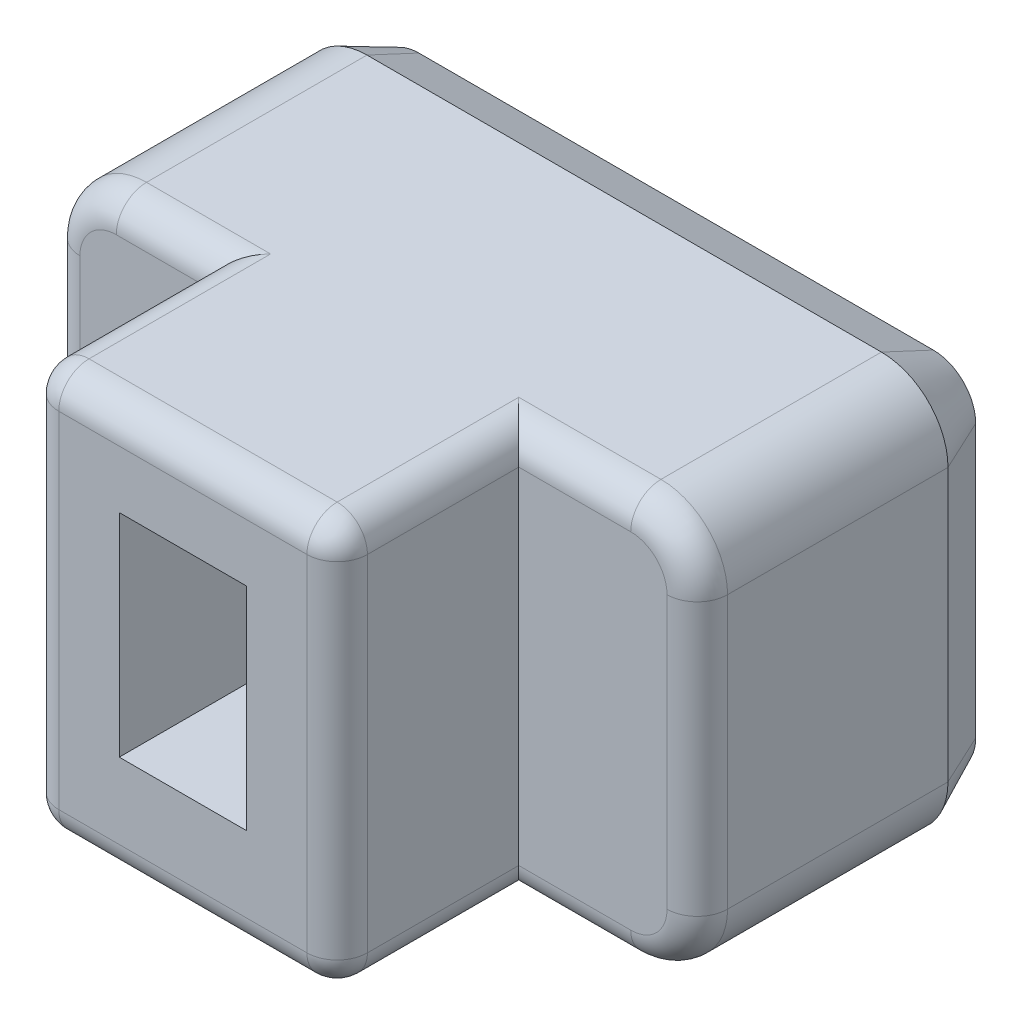
from build123d import *

# Parameters (mm, degrees)
BOSS_EXTRU_1_DEPTH      = 8
ESQUISSE3_W             = 2.1
ESQUISSE3_H             = 3.5
ENL_V_MAT_EXTRU_1_DEPTH = 3
ESQUISSE4_OUTSIDE_W     = 15.69
ESQUISSE4_OUTSIDE_H     = 11.69
ESQUISSE4_OUTSIDE_W_2   = 5.1
ESQUISSE4_OUTSIDE_H_2   = 6.7
ENL_V_MAT_EXTRU_2_DEPTH = 3
CONG_1_R                = 0.5
CHANFREIN1_SIZE         = 0.4
CHANFREIN1_SIZE2        = 0.857802768
ESQUISSE5_W             = 0.443661971
ESQUISSE5_H             = 3.5
ENL_V_MAT_EXTRU_3_DEPTH = 0.2
BOSS_EXTRU_2_DEPTH      = 0.2
BOSS_EXTRU_2_2_DEPTH    = 0.2
ESQUISSE5_4_W           = 0.443661971
ESQUISSE5_4_H           = 3.5
BOSS_EXTRU_2_3_DEPTH    = 0.2


with BuildPart() as part:
    # Esquisse2 → Boss.-Extru.1 (new body)
    with BuildSketch(Plane.XY):
        with BuildLine():
            Line((1.1, 0), (9.6, 0))
            ThreePointArc((9.6, 0), (10.377817459, 0.322182541), (10.7, 1.1))
            Line((10.7, 1.1), (10.7, 5.6))
            ThreePointArc((10.7, 5.6), (10.377817459, 6.377817459), (9.6, 6.7))
            Line((9.6, 6.7), (1.1, 6.7))
            ThreePointArc((1.1, 6.7), (0.322182541, 6.377817459), (0, 5.6))
            Line((0, 5.6), (0, 1.1))
            ThreePointArc((0, 1.1), (0.322182541, 0.322182541), (1.1, 0))
        make_face()
    extrude(amount=BOSS_EXTRU_1_DEPTH)

    # Esquisse3 → Enlèv. mat.-Extru.1 (cut)
    with BuildSketch(Plane.XY.offset(8)):
        with Locations((5.2, 3.5)):
            Rectangle(ESQUISSE3_W, ESQUISSE3_H)
    extrude(amount=-ENL_V_MAT_EXTRU_1_DEPTH, mode=Mode.SUBTRACT)

    # Esquisse4 outside → Enlèv. mat.-Extru.2 (cut)
    with BuildSketch(Plane.XY.offset(8)):
        with Locations((5.35, 3.35)):
            Rectangle(ESQUISSE4_OUTSIDE_W, ESQUISSE4_OUTSIDE_H)
        with Locations((5.2, 3.35)):
            Rectangle(ESQUISSE4_OUTSIDE_W_2, ESQUISSE4_OUTSIDE_H_2, mode=Mode.SUBTRACT)
    extrude(amount=-ENL_V_MAT_EXTRU_2_DEPTH, mode=Mode.SUBTRACT)

    # Congé1
    cong_1_edges = [part.edges().sort_by_distance(p)[0] for p in [
        (8.675, 0, 5),
        (10.377817459, 0.322182541, 5),
        (10.7, 3.35, 5),
        (10.377817459, 6.377817459, 5),
        (1.875, 6.7, 5),
        (0.322182541, 6.377817459, 5),
        (1.875, 0, 5),
        (0.322182541, 0.322182541, 5),
        (7.75, 6.7, 6.5),
        (2.65, 6.7, 6.5),
        (7.75, 0, 6.5),
        (2.65, 0, 6.5),
        (2.65, 3.35, 8),
        (5.2, 6.7, 8),
        (7.75, 3.35, 8),
        (5.2, 0, 8),
        (8.675, 6.7, 5),
        (0, 3.35, 5),
    ]]
    fillet(cong_1_edges, radius=CONG_1_R)

    # Chanfrein1
    chanfrein1_edges = [part.edges().sort_by_distance(p)[0] for p in [
        (5.35, 0, 0),
        (10.377817459, 0.322182541, 0),
        (0.322182541, 0.322182541, 0),
        (10.7, 3.35, 0),
        (0, 3.35, 0),
        (10.377817459, 6.377817459, 0),
        (0.322182541, 6.377817459, 0),
        (5.35, 6.7, 0),
    ]]
    chanfrein1_side = [part.faces().sort_by_distance(p)[0] for p in [
        (5.35, 3.35, 0),
    ]]
    chamfer(chanfrein1_edges, length=CHANFREIN1_SIZE, length2=CHANFREIN1_SIZE2, reference=chanfrein1_side[0])

    # Esquisse5 → Enlèv. mat.-Extru.3 (cut)
    # profile 1 of 3: a face of its own
    with BuildSketch(Plane.XY):
        with BuildLine():
            add(Edge.make_bspline(
                [(3.442119312, 1.938069324), (3.395066193, 1.938910772), (3.302153597, 1.940572322), (3.165772884, 1.959585223), (3.033480986, 1.9865083), (2.906821659, 2.027013155), (2.785549912, 2.077136818), (2.672670174, 2.140088534), (2.567734941, 2.213495328), (2.472020347, 2.298905726), (2.384541306, 2.394549003), (2.306892222, 2.501721356), (2.240446849, 2.620291238), (2.181769344, 2.748647547), (2.135878101, 2.888915832), (2.101782213, 3.039930676), (2.082925754, 3.20233784), (2.080192642, 3.313939587), (2.078783044, 3.371498021)],
                knots=[0, 0, 0, 0, 1.010713025, 1.995786298, 2.954820268, 3.909604824, 4.84953527, 5.771007602, 6.682058279, 7.596879091, 8.52277019, 9.463332336, 10.434705207, 11.4400245, 12.492415661, 13.601058905, 14.762749715, 16, 16, 16, 16], degree=3))
            add(Edge.make_bspline(
                [(2.078783044, 3.371498021), (2.079924859, 3.428285975), (2.082142615, 3.538585721), (2.100387971, 3.698284797), (2.132134357, 3.846191315), (2.174876342, 3.982683971), (2.230167977, 4.107269116), (2.294540482, 4.221517301), (2.370844541, 4.323766735), (2.456519919, 4.415457029), (2.552952802, 4.495031079), (2.658512678, 4.564174912), (2.773555911, 4.621942146), (2.897787738, 4.667825284), (3.02968821, 4.704210486), (3.169474567, 4.729011378), (3.316205366, 4.744852079), (3.416402337, 4.746888963), (3.467537446, 4.747928478)],
                knots=[0, 0, 0, 0, 1.222566562, 2.374601885, 3.454571273, 4.475627065, 5.44839755, 6.384388942, 7.293261178, 8.188871665, 9.080034862, 9.978575306, 10.90076714, 11.845452766, 12.825859322, 13.842986405, 14.899177044, 16, 16, 16, 16], degree=3))
            add(Edge.make_bspline(
                [(3.467537446, 4.747928478), (3.497077269, 4.747756903), (3.558017547, 4.747402944), (3.650917954, 4.740187531), (3.746845258, 4.732574634), (3.843310634, 4.719697556), (3.939155709, 4.705397767), (4.031601512, 4.688612545), (4.118094427, 4.670829677), (4.172627532, 4.656252994), (4.198501354, 4.649336929)],
                knots=[0, 0, 0, 0, 0.958487045, 1.977346509, 3.023048326, 4.081489793, 5.135130748, 6.168204709, 7.130884884, 8, 8, 8, 8], degree=3))
            Line((4.198501354, 4.649336929), (4.198501354, 5.019055239))
            add(Edge.make_bspline(
                [(4.198501354, 5.019055239), (4.171891989, 5.028574955), (4.117351664, 5.0480872), (4.031270221, 5.072848876), (3.939055541, 5.093142904), (3.807669886, 5.116831328), (3.636636044, 5.138394566), (3.497652561, 5.140986233), (3.427484629, 5.142294676)],
                knots=[0, 0, 0, 0, 0.64817905, 1.328550917, 2.052973816, 2.813122394, 4.391056218, 6, 6, 6, 6], degree=3))
            add(Edge.make_bspline(
                [(3.427484629, 5.142294676), (3.357075444, 5.140826497), (3.219995444, 5.137968093), (3.020757882, 5.115533024), (2.833971161, 5.078189546), (2.659970346, 5.024823864), (2.498802115, 4.957896391), (2.350125012, 4.878441577), (2.215448613, 4.784882224), (2.094283086, 4.677766078), (1.987140454, 4.557842568), (1.892465469, 4.425953407), (1.814624509, 4.280040443), (1.748848028, 4.123085375), (1.697006767, 3.9546993), (1.661682518, 3.774744734), (1.638427133, 3.584439174), (1.636239514, 3.453729532), (1.635121073, 3.38690295)],
                knots=[0, 0, 0, 0, 1.184649013, 2.306399189, 3.36898292, 4.385816993, 5.363947997, 6.301541167, 7.217245905, 8.117147173, 9.016695713, 9.918265376, 10.842401924, 11.79328093, 12.778666145, 13.801422125, 14.875955582, 16, 16, 16, 16], degree=3))
            add(Edge.make_bspline(
                [(1.635121073, 3.38690295), (1.63652538, 3.320843721), (1.639288242, 3.190877444), (1.663308294, 3.000284905), (1.700302314, 2.817243304), (1.754667164, 2.643460839), (1.821836851, 2.479051191), (1.904013284, 2.326258247), (1.999795792, 2.185573787), (2.10872572, 2.056935937), (2.231154394, 1.941746033), (2.365976512, 1.839579054), (2.513043826, 1.750628048), (2.672006774, 1.675953383), (2.841975297, 1.616334738), (3.022719606, 1.574247144), (3.21362756, 1.548296445), (3.344470487, 1.54525619), (3.411309453, 1.543703126)],
                knots=[0, 0, 0, 0, 1.099381571, 2.162945759, 3.193245675, 4.204563685, 5.189679354, 6.145919907, 7.087284112, 8.018274975, 8.946592887, 9.88016098, 10.829497872, 11.802783365, 12.799112124, 13.822445575, 14.887631986, 16, 16, 16, 16], degree=3))
            add(Edge.make_bspline(
                [(3.411309453, 1.543703126), (3.447001192, 1.544253256), (3.518435413, 1.545354297), (3.624419175, 1.550915785), (3.727566932, 1.563228075), (3.82638564, 1.577132749), (3.91938219, 1.595742162), (4.004794207, 1.616820876), (4.080906052, 1.640362569), (4.127469434, 1.65848355), (4.14920558, 1.666942563)],
                knots=[0, 0, 0, 0, 1.138607152, 2.278833004, 3.383081621, 4.45092605, 5.46116126, 6.40661541, 7.25619579, 8, 8, 8, 8], degree=3))
            Line((4.14920558, 1.666942563), (4.14920558, 2.036660873))
            add(Edge.make_bspline(
                [(4.14920558, 2.036660873), (4.095425956, 2.023181548), (3.983688555, 1.995175686), (3.809263405, 1.9649167), (3.62732109, 1.94170611), (3.503813346, 1.939280802), (3.442119312, 1.938069324)],
                knots=[0, 0, 0, 0, 0.92915897, 1.930504546, 2.966254919, 4, 4, 4, 4], degree=3))
        make_face()
    # profile 2 of 3: a face of its own
    with BuildSketch(Plane.XY):
        with BuildLine():
            add(Edge.make_bspline(
                [(7.747797129, 3.327593971), (7.746919878, 3.377945997), (7.745193276, 3.477048625), (7.731197663, 3.623559869), (7.706970704, 3.765198254), (7.675164776, 3.902660023), (7.632949757, 4.034428836), (7.580365712, 4.159552876), (7.518574412, 4.277839122), (7.447611708, 4.389517104), (7.366196496, 4.493311013), (7.276824072, 4.591258519), (7.176888246, 4.680552099), (7.067749349, 4.762660281), (6.948916125, 4.836610737), (6.820485318, 4.901932876), (6.682998819, 4.959797651), (6.586304596, 4.989345019), (6.536969664, 5.004420556)],
                knots=[0, 0, 0, 0, 1.07890696, 2.123499795, 3.15014457, 4.15640317, 5.144722051, 6.111393237, 7.061337734, 8.001528439, 8.942523758, 9.884837156, 10.839359572, 11.809921804, 12.808388495, 13.834502369, 14.895128641, 16, 16, 16, 16], degree=3))
            add(Edge.make_bspline(
                [(6.536969664, 5.004420556), (6.477123779, 5.019478053), (6.353629302, 5.050549824), (6.157038434, 5.075157068), (5.945699193, 5.091007195), (5.799366536, 5.092319391), (5.723589382, 5.092998901)],
                knots=[0, 0, 0, 0, 0.901675841, 1.860645644, 2.892153085, 4, 4, 4, 4], degree=3))
            Line((5.723589382, 5.092998901), (4.937937974, 5.092998901))
            Line((4.937937974, 5.092998901), (4.937937974, 1.592998901))
            Line((4.937937974, 1.592998901), (5.731291847, 1.592998901))
            add(Edge.make_bspline(
                [(5.731291847, 1.592998901), (5.80705817, 1.593803384), (5.953351683, 1.59535672), (6.164853586, 1.609531217), (6.361259726, 1.635733521), (6.484814033, 1.666615782), (6.544672129, 1.681577246)],
                knots=[0, 0, 0, 0, 1.107776242, 2.138951362, 3.09838168, 4, 4, 4, 4], degree=3))
            add(Edge.make_bspline(
                [(6.544672129, 1.681577246), (6.593992838, 1.696694486), (6.690565445, 1.726294858), (6.827952135, 1.783431759), (6.956789132, 1.846929966), (7.075415555, 1.920275819), (7.184076501, 2.001343391), (7.283689973, 2.088792723), (7.373144821, 2.183702531), (7.452990132, 2.285726397), (7.522297297, 2.395267491), (7.583487637, 2.510639129), (7.63419685, 2.633038831), (7.675879799, 2.761301954), (7.708103611, 2.895513103), (7.730968439, 3.035040873), (7.745262408, 3.179665011), (7.746943086, 3.277751165), (7.747797129, 3.327593971)],
                knots=[0, 0, 0, 0, 1.11957884, 2.192195745, 3.226934197, 4.235753686, 5.215895448, 6.167834449, 7.110454323, 8.043928443, 8.976536385, 9.92172489, 10.87638654, 11.849622111, 12.84758352, 13.87047839, 14.91787649, 16, 16, 16, 16], degree=3))
        make_face()
        with BuildLine():
            add(Edge.make_bspline(
                [(7.304135157, 3.327593971), (7.303757768, 3.28673543), (7.303020555, 3.20692003), (7.291018211, 3.090317453), (7.276254909, 2.979331998), (7.251268266, 2.874644852), (7.222485673, 2.775141843), (7.183562928, 2.682603272), (7.141217125, 2.594660002), (7.089881546, 2.513833439), (7.032561991, 2.438903931), (6.969944629, 2.369118826), (6.901341171, 2.304913109), (6.826138714, 2.247280798), (6.745673953, 2.19451906), (6.659379046, 2.147663573), (6.56716723, 2.106443035), (6.502750067, 2.084190308), (6.46995822, 2.072862457)],
                knots=[0, 0, 0, 0, 1.203908281, 2.351782981, 3.453299741, 4.501757918, 5.521853172, 6.50298295, 7.457592397, 8.39634505, 9.319837418, 10.236354763, 11.157517625, 12.085620599, 13.02617201, 13.991524509, 14.977576495, 16, 16, 16, 16], degree=3))
            add(Edge.make_bspline(
                [(6.46995822, 2.072862457), (6.44358053, 2.065172173), (6.389635601, 2.049444799), (6.305907885, 2.030100681), (6.217559531, 2.015980705), (6.124867934, 2.004041996), (6.026372797, 1.99682558), (5.922092752, 1.991754684), (5.811690037, 1.987333823), (5.736174884, 1.987354488), (5.697401002, 1.987365098)],
                knots=[0, 0, 0, 0, 0.845047478, 1.728203794, 2.640913837, 3.595964267, 4.602025111, 5.677478979, 6.80748229, 8, 8, 8, 8], degree=3))
            Line((5.697401002, 1.987365098), (5.381599946, 1.987365098))
            Line((5.381599946, 1.987365098), (5.381599946, 4.698632704))
            Line((5.381599946, 4.698632704), (5.697401002, 4.698632704))
            add(Edge.make_bspline(
                [(5.697401002, 4.698632704), (5.736175829, 4.698653675), (5.811692822, 4.698694519), (5.922082498, 4.694130687), (6.026429396, 4.689560114), (6.124758868, 4.680633051), (6.217627186, 4.670340999), (6.305898482, 4.655814082), (6.389637803, 4.636572448), (6.443581253, 4.620832014), (6.46995822, 4.613135345)],
                knots=[0, 0, 0, 0, 1.192561933, 2.322607149, 3.398100897, 4.404849775, 5.358988228, 6.271732119, 7.154921185, 8, 8, 8, 8], degree=3))
            add(Edge.make_bspline(
                [(6.46995822, 4.613135345), (6.502777786, 4.601870667), (6.567349031, 4.579707843), (6.659369007, 4.537478133), (6.745904942, 4.489995917), (6.826391425, 4.435612923), (6.90140197, 4.375628239), (6.969941665, 4.30909147), (7.033086903, 4.236884004), (7.08966102, 4.158290147), (7.141059031, 4.074500251), (7.183786674, 3.983935965), (7.222144467, 3.888871425), (7.251443881, 3.787255047), (7.276130676, 3.680690725), (7.291039786, 3.567953468), (7.303012071, 3.449803293), (7.303754963, 3.368964956), (7.304135157, 3.327593971)],
                knots=[0, 0, 0, 0, 1.006800501, 1.980841591, 2.935030726, 3.86945153, 4.797219232, 5.719702176, 6.638957378, 7.578240975, 8.528023958, 9.488133661, 10.481937626, 11.500724106, 12.554967205, 13.654405842, 14.799585148, 16, 16, 16, 16], degree=3))
        make_face(mode=Mode.SUBTRACT)
    # profile 3 of 3: a face of its own
    with BuildSketch(Plane.XY):
        with Locations((8.709064735, 3.342998901)):
            Rectangle(ESQUISSE5_W, ESQUISSE5_H)
    extrude(amount=ENL_V_MAT_EXTRU_3_DEPTH, mode=Mode.SUBTRACT)


with BuildPart() as body_2:
    # Esquisse5_4 → Boss.-Extru.2 (new body)
    with BuildSketch(Plane.XY):
        with BuildLine():
            add(Edge.make_bspline(
                [(3.442119312, 1.938069324), (3.395066193, 1.938910772), (3.302153597, 1.940572322), (3.165772884, 1.959585223), (3.033480986, 1.9865083), (2.906821659, 2.027013155), (2.785549912, 2.077136818), (2.672670174, 2.140088534), (2.567734941, 2.213495328), (2.472020347, 2.298905726), (2.384541306, 2.394549003), (2.306892222, 2.501721356), (2.240446849, 2.620291238), (2.181769344, 2.748647547), (2.135878101, 2.888915832), (2.101782213, 3.039930676), (2.082925754, 3.20233784), (2.080192642, 3.313939587), (2.078783044, 3.371498021)],
                knots=[0, 0, 0, 0, 1.010713025, 1.995786298, 2.954820268, 3.909604824, 4.84953527, 5.771007602, 6.682058279, 7.596879091, 8.52277019, 9.463332336, 10.434705207, 11.4400245, 12.492415661, 13.601058905, 14.762749715, 16, 16, 16, 16], degree=3))
            add(Edge.make_bspline(
                [(2.078783044, 3.371498021), (2.079924859, 3.428285975), (2.082142615, 3.538585721), (2.100387971, 3.698284797), (2.132134357, 3.846191315), (2.174876342, 3.982683971), (2.230167977, 4.107269116), (2.294540482, 4.221517301), (2.370844541, 4.323766735), (2.456519919, 4.415457029), (2.552952802, 4.495031079), (2.658512678, 4.564174912), (2.773555911, 4.621942146), (2.897787738, 4.667825284), (3.02968821, 4.704210486), (3.169474567, 4.729011378), (3.316205366, 4.744852079), (3.416402337, 4.746888963), (3.467537446, 4.747928478)],
                knots=[0, 0, 0, 0, 1.222566562, 2.374601885, 3.454571273, 4.475627065, 5.44839755, 6.384388942, 7.293261178, 8.188871665, 9.080034862, 9.978575306, 10.90076714, 11.845452766, 12.825859322, 13.842986405, 14.899177044, 16, 16, 16, 16], degree=3))
            add(Edge.make_bspline(
                [(3.467537446, 4.747928478), (3.497077269, 4.747756903), (3.558017547, 4.747402944), (3.650917954, 4.740187531), (3.746845258, 4.732574634), (3.843310634, 4.719697556), (3.939155709, 4.705397767), (4.031601512, 4.688612545), (4.118094427, 4.670829677), (4.172627532, 4.656252994), (4.198501354, 4.649336929)],
                knots=[0, 0, 0, 0, 0.958487045, 1.977346509, 3.023048326, 4.081489793, 5.135130748, 6.168204709, 7.130884884, 8, 8, 8, 8], degree=3))
            Line((4.198501354, 4.649336929), (4.198501354, 5.019055239))
            add(Edge.make_bspline(
                [(4.198501354, 5.019055239), (4.171891989, 5.028574955), (4.117351664, 5.0480872), (4.031270221, 5.072848876), (3.939055541, 5.093142904), (3.807669886, 5.116831328), (3.636636044, 5.138394566), (3.497652561, 5.140986233), (3.427484629, 5.142294676)],
                knots=[0, 0, 0, 0, 0.64817905, 1.328550917, 2.052973816, 2.813122394, 4.391056218, 6, 6, 6, 6], degree=3))
            add(Edge.make_bspline(
                [(3.427484629, 5.142294676), (3.357075444, 5.140826497), (3.219995444, 5.137968093), (3.020757882, 5.115533024), (2.833971161, 5.078189546), (2.659970346, 5.024823864), (2.498802115, 4.957896391), (2.350125012, 4.878441577), (2.215448613, 4.784882224), (2.094283086, 4.677766078), (1.987140454, 4.557842568), (1.892465469, 4.425953407), (1.814624509, 4.280040443), (1.748848028, 4.123085375), (1.697006767, 3.9546993), (1.661682518, 3.774744734), (1.638427133, 3.584439174), (1.636239514, 3.453729532), (1.635121073, 3.38690295)],
                knots=[0, 0, 0, 0, 1.184649013, 2.306399189, 3.36898292, 4.385816993, 5.363947997, 6.301541167, 7.217245905, 8.117147173, 9.016695713, 9.918265376, 10.842401924, 11.79328093, 12.778666145, 13.801422125, 14.875955582, 16, 16, 16, 16], degree=3))
            add(Edge.make_bspline(
                [(1.635121073, 3.38690295), (1.63652538, 3.320843721), (1.639288242, 3.190877444), (1.663308294, 3.000284905), (1.700302314, 2.817243304), (1.754667164, 2.643460839), (1.821836851, 2.479051191), (1.904013284, 2.326258247), (1.999795792, 2.185573787), (2.10872572, 2.056935937), (2.231154394, 1.941746033), (2.365976512, 1.839579054), (2.513043826, 1.750628048), (2.672006774, 1.675953383), (2.841975297, 1.616334738), (3.022719606, 1.574247144), (3.21362756, 1.548296445), (3.344470487, 1.54525619), (3.411309453, 1.543703126)],
                knots=[0, 0, 0, 0, 1.099381571, 2.162945759, 3.193245675, 4.204563685, 5.189679354, 6.145919907, 7.087284112, 8.018274975, 8.946592887, 9.88016098, 10.829497872, 11.802783365, 12.799112124, 13.822445575, 14.887631986, 16, 16, 16, 16], degree=3))
            add(Edge.make_bspline(
                [(3.411309453, 1.543703126), (3.447001192, 1.544253256), (3.518435413, 1.545354297), (3.624419175, 1.550915785), (3.727566932, 1.563228075), (3.82638564, 1.577132749), (3.91938219, 1.595742162), (4.004794207, 1.616820876), (4.080906052, 1.640362569), (4.127469434, 1.65848355), (4.14920558, 1.666942563)],
                knots=[0, 0, 0, 0, 1.138607152, 2.278833004, 3.383081621, 4.45092605, 5.46116126, 6.40661541, 7.25619579, 8, 8, 8, 8], degree=3))
            Line((4.14920558, 1.666942563), (4.14920558, 2.036660873))
            add(Edge.make_bspline(
                [(4.14920558, 2.036660873), (4.095425956, 2.023181548), (3.983688555, 1.995175686), (3.809263405, 1.9649167), (3.62732109, 1.94170611), (3.503813346, 1.939280802), (3.442119312, 1.938069324)],
                knots=[0, 0, 0, 0, 0.92915897, 1.930504546, 2.966254919, 4, 4, 4, 4], degree=3))
        make_face()
    extrude(amount=-BOSS_EXTRU_2_DEPTH)


with BuildPart() as body_3:
    # Esquisse5_4 → Boss.-Extru.2 2 (new body)
    with BuildSketch(Plane.XY):
        with BuildLine():
            add(Edge.make_bspline(
                [(7.747797129, 3.327593971), (7.746919878, 3.377945997), (7.745193276, 3.477048625), (7.731197663, 3.623559869), (7.706970704, 3.765198254), (7.675164776, 3.902660023), (7.632949757, 4.034428836), (7.580365712, 4.159552876), (7.518574412, 4.277839122), (7.447611708, 4.389517104), (7.366196496, 4.493311013), (7.276824072, 4.591258519), (7.176888246, 4.680552099), (7.067749349, 4.762660281), (6.948916125, 4.836610737), (6.820485318, 4.901932876), (6.682998819, 4.959797651), (6.586304596, 4.989345019), (6.536969664, 5.004420556)],
                knots=[0, 0, 0, 0, 1.07890696, 2.123499795, 3.15014457, 4.15640317, 5.144722051, 6.111393237, 7.061337734, 8.001528439, 8.942523758, 9.884837156, 10.839359572, 11.809921804, 12.808388495, 13.834502369, 14.895128641, 16, 16, 16, 16], degree=3))
            add(Edge.make_bspline(
                [(6.536969664, 5.004420556), (6.477123779, 5.019478053), (6.353629302, 5.050549824), (6.157038434, 5.075157068), (5.945699193, 5.091007195), (5.799366536, 5.092319391), (5.723589382, 5.092998901)],
                knots=[0, 0, 0, 0, 0.901675841, 1.860645644, 2.892153085, 4, 4, 4, 4], degree=3))
            Line((5.723589382, 5.092998901), (4.937937974, 5.092998901))
            Line((4.937937974, 5.092998901), (4.937937974, 1.592998901))
            Line((4.937937974, 1.592998901), (5.731291847, 1.592998901))
            add(Edge.make_bspline(
                [(5.731291847, 1.592998901), (5.80705817, 1.593803384), (5.953351683, 1.59535672), (6.164853586, 1.609531217), (6.361259726, 1.635733521), (6.484814033, 1.666615782), (6.544672129, 1.681577246)],
                knots=[0, 0, 0, 0, 1.107776242, 2.138951362, 3.09838168, 4, 4, 4, 4], degree=3))
            add(Edge.make_bspline(
                [(6.544672129, 1.681577246), (6.593992838, 1.696694486), (6.690565445, 1.726294858), (6.827952135, 1.783431759), (6.956789132, 1.846929966), (7.075415555, 1.920275819), (7.184076501, 2.001343391), (7.283689973, 2.088792723), (7.373144821, 2.183702531), (7.452990132, 2.285726397), (7.522297297, 2.395267491), (7.583487637, 2.510639129), (7.63419685, 2.633038831), (7.675879799, 2.761301954), (7.708103611, 2.895513103), (7.730968439, 3.035040873), (7.745262408, 3.179665011), (7.746943086, 3.277751165), (7.747797129, 3.327593971)],
                knots=[0, 0, 0, 0, 1.11957884, 2.192195745, 3.226934197, 4.235753686, 5.215895448, 6.167834449, 7.110454323, 8.043928443, 8.976536385, 9.92172489, 10.87638654, 11.849622111, 12.84758352, 13.87047839, 14.91787649, 16, 16, 16, 16], degree=3))
        make_face()
        with BuildLine():
            add(Edge.make_bspline(
                [(7.304135157, 3.327593971), (7.303757768, 3.28673543), (7.303020555, 3.20692003), (7.291018211, 3.090317453), (7.276254909, 2.979331998), (7.251268266, 2.874644852), (7.222485673, 2.775141843), (7.183562928, 2.682603272), (7.141217125, 2.594660002), (7.089881546, 2.513833439), (7.032561991, 2.438903931), (6.969944629, 2.369118826), (6.901341171, 2.304913109), (6.826138714, 2.247280798), (6.745673953, 2.19451906), (6.659379046, 2.147663573), (6.56716723, 2.106443035), (6.502750067, 2.084190308), (6.46995822, 2.072862457)],
                knots=[0, 0, 0, 0, 1.203908281, 2.351782981, 3.453299741, 4.501757918, 5.521853172, 6.50298295, 7.457592397, 8.39634505, 9.319837418, 10.236354763, 11.157517625, 12.085620599, 13.02617201, 13.991524509, 14.977576495, 16, 16, 16, 16], degree=3))
            add(Edge.make_bspline(
                [(6.46995822, 2.072862457), (6.44358053, 2.065172173), (6.389635601, 2.049444799), (6.305907885, 2.030100681), (6.217559531, 2.015980705), (6.124867934, 2.004041996), (6.026372797, 1.99682558), (5.922092752, 1.991754684), (5.811690037, 1.987333823), (5.736174884, 1.987354488), (5.697401002, 1.987365098)],
                knots=[0, 0, 0, 0, 0.845047478, 1.728203794, 2.640913837, 3.595964267, 4.602025111, 5.677478979, 6.80748229, 8, 8, 8, 8], degree=3))
            Line((5.697401002, 1.987365098), (5.381599946, 1.987365098))
            Line((5.381599946, 1.987365098), (5.381599946, 4.698632704))
            Line((5.381599946, 4.698632704), (5.697401002, 4.698632704))
            add(Edge.make_bspline(
                [(5.697401002, 4.698632704), (5.736175829, 4.698653675), (5.811692822, 4.698694519), (5.922082498, 4.694130687), (6.026429396, 4.689560114), (6.124758868, 4.680633051), (6.217627186, 4.670340999), (6.305898482, 4.655814082), (6.389637803, 4.636572448), (6.443581253, 4.620832014), (6.46995822, 4.613135345)],
                knots=[0, 0, 0, 0, 1.192561933, 2.322607149, 3.398100897, 4.404849775, 5.358988228, 6.271732119, 7.154921185, 8, 8, 8, 8], degree=3))
            add(Edge.make_bspline(
                [(6.46995822, 4.613135345), (6.502777786, 4.601870667), (6.567349031, 4.579707843), (6.659369007, 4.537478133), (6.745904942, 4.489995917), (6.826391425, 4.435612923), (6.90140197, 4.375628239), (6.969941665, 4.30909147), (7.033086903, 4.236884004), (7.08966102, 4.158290147), (7.141059031, 4.074500251), (7.183786674, 3.983935965), (7.222144467, 3.888871425), (7.251443881, 3.787255047), (7.276130676, 3.680690725), (7.291039786, 3.567953468), (7.303012071, 3.449803293), (7.303754963, 3.368964956), (7.304135157, 3.327593971)],
                knots=[0, 0, 0, 0, 1.006800501, 1.980841591, 2.935030726, 3.86945153, 4.797219232, 5.719702176, 6.638957378, 7.578240975, 8.528023958, 9.488133661, 10.481937626, 11.500724106, 12.554967205, 13.654405842, 14.799585148, 16, 16, 16, 16], degree=3))
        make_face(mode=Mode.SUBTRACT)
    extrude(amount=-BOSS_EXTRU_2_2_DEPTH)


with BuildPart() as body_4:
    # Esquisse5_4 → Boss.-Extru.2 3 (new body)
    with BuildSketch(Plane.XY):
        with Locations((8.709064735, 3.342998901)):
            Rectangle(ESQUISSE5_4_W, ESQUISSE5_4_H)
    extrude(amount=-BOSS_EXTRU_2_3_DEPTH)


solid = Compound([part.part, body_2.part, body_3.part, body_4.part])
